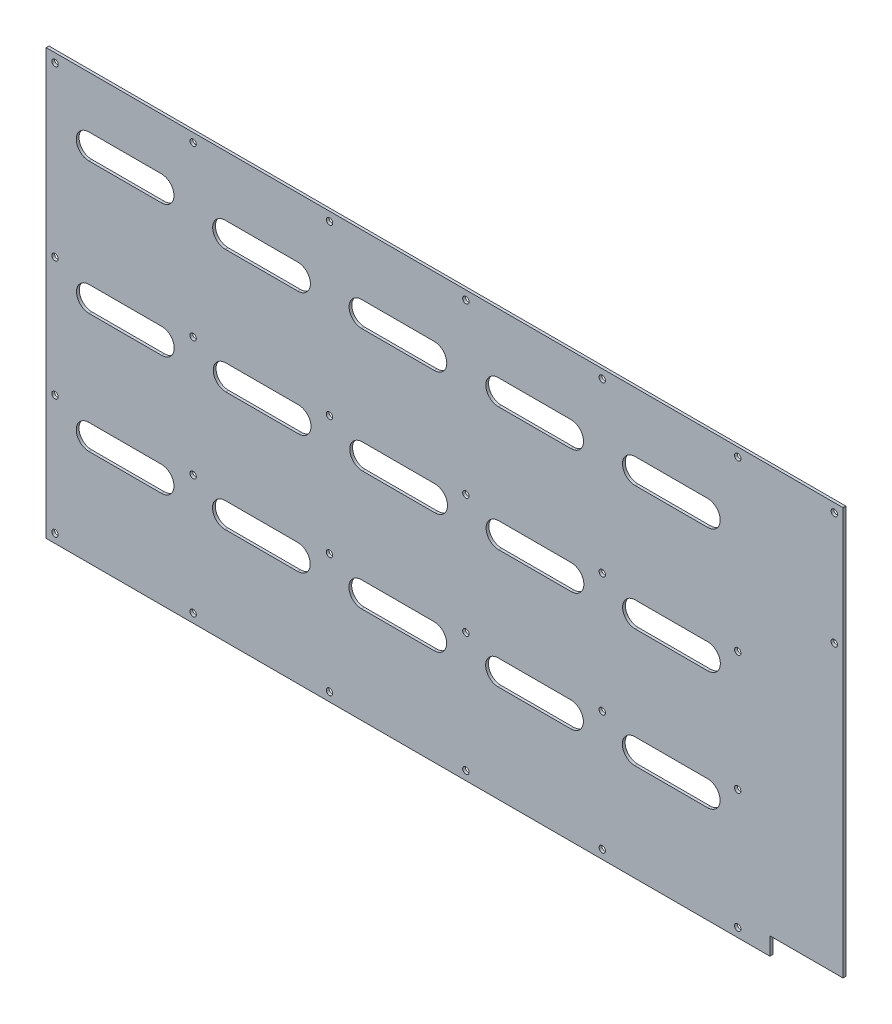
from build123d import *

# Parameters (mm, degrees)
MODEL_R             = 1.8288
BOSS_EXTRUDE2_DEPTH = 1.5875


with BuildPart() as part:
    # Model → Boss-Extrude2 (new body)
    with BuildSketch(Plane.XY):
        with BuildLine():
            ThreePointArc((0, 0.0635), (0.044901281, 0.044901281), (0.0635, 0))
            Line((0.0635, 0), (415.2265, 0))
            ThreePointArc((415.2265, 0), (415.245098719, 0.044901281), (415.29, 0.0635))
            Line((415.29, 0.0635), (415.29, 10.0965))
            ThreePointArc((415.29, 10.0965), (415.245098719, 10.204901281), (415.3535, 10.16))
            Line((415.3535, 10.16), (457.1365, 10.16))
            ThreePointArc((457.1365, 10.16), (457.155098719, 10.204901281), (457.2, 10.2235))
            Line((457.2, 10.2235), (457.2, 243.7765))
            ThreePointArc((457.2, 243.7765), (457.155098719, 243.795098719), (457.1365, 243.84))
            Line((457.1365, 243.84), (0.0635, 243.84))
            ThreePointArc((0.0635, 243.84), (0.044901281, 243.795098719), (0, 243.7765))
            Line((0, 243.7765), (0, 0.0635))
        make_face()
        with Locations((5.08, 5.08)):
            Circle(MODEL_R, mode=Mode.SUBTRACT)
        with Locations((84.328, 5.08)):
            Circle(MODEL_R, mode=Mode.SUBTRACT)
        with Locations((162.56, 5.08)):
            Circle(MODEL_R, mode=Mode.SUBTRACT)
        with Locations((5.08, 73.66)):
            Circle(MODEL_R, mode=Mode.SUBTRACT)
        with BuildLine():
            ThreePointArc((24.423491284, 69.864294681), (24.486850673, 69.928074512), (24.550490667, 69.864574667))
            Line((24.550490667, 69.864574667), (66.079490667, 69.864574667))
            ThreePointArc((66.079490667, 69.864574667), (66.142990667, 69.928074667), (66.206490667, 69.864574667))
            ThreePointArc((66.206490667, 69.864574667), (66.206490512, 69.864434673), (66.206490049, 69.864294681))
            ThreePointArc((66.206490049, 69.864294681), (73.343728337, 62.632017), (66.142990667, 55.462959333))
            Line((66.142990667, 55.462959333), (24.486990667, 55.462959333))
            ThreePointArc((24.486990667, 55.462959333), (17.286252997, 62.632017), (24.423491284, 69.864294681))
        make_face(mode=Mode.SUBTRACT)
        with Locations((84.328, 73.66)):
            Circle(MODEL_R, mode=Mode.SUBTRACT)
        with BuildLine():
            ThreePointArc((102.595635284, 70.154387347), (102.658994673, 70.218167179), (102.722634667, 70.154667333))
            Line((102.722634667, 70.154667333), (144.251634667, 70.154667333))
            ThreePointArc((144.251634667, 70.154667333), (144.315134667, 70.218167333), (144.378634667, 70.154667333))
            ThreePointArc((144.378634667, 70.154667333), (144.378634512, 70.15452734), (144.378634049, 70.154387347))
            ThreePointArc((144.378634049, 70.154387347), (151.515872337, 62.922109667), (144.315134667, 55.753052))
            Line((144.315134667, 55.753052), (102.659134667, 55.753052))
            ThreePointArc((102.659134667, 55.753052), (95.458396997, 62.922109667), (102.595635284, 70.154387347))
        make_face(mode=Mode.SUBTRACT)
        with Locations((162.56, 73.66)):
            Circle(MODEL_R, mode=Mode.SUBTRACT)
        with BuildLine():
            ThreePointArc((180.831401284, 69.892675347), (180.894760673, 69.956455179), (180.958400667, 69.892955333))
            Line((180.958400667, 69.892955333), (222.487400667, 69.892955333))
            ThreePointArc((222.487400667, 69.892955333), (222.550900667, 69.956455333), (222.614400667, 69.892955333))
            ThreePointArc((222.614400667, 69.892955333), (222.614400512, 69.89281534), (222.614400049, 69.892675347))
            ThreePointArc((222.614400049, 69.892675347), (229.751638337, 62.660397667), (222.550900667, 55.49134))
            Line((222.550900667, 55.49134), (180.894900667, 55.49134))
            ThreePointArc((180.894900667, 55.49134), (173.694162997, 62.660397667), (180.831401284, 69.892675347))
        make_face(mode=Mode.SUBTRACT)
        with Locations((240.792, 5.08)):
            Circle(MODEL_R, mode=Mode.SUBTRACT)
        with Locations((319.024, 5.08)):
            Circle(MODEL_R, mode=Mode.SUBTRACT)
        with Locations((396.748, 5.08)):
            Circle(MODEL_R, mode=Mode.SUBTRACT)
        with Locations((240.792, 73.66)):
            Circle(MODEL_R, mode=Mode.SUBTRACT)
        with BuildLine():
            ThreePointArc((259.275886617, 70.272664014), (259.339246007, 70.336443846), (259.402886, 70.272944))
            Line((259.402886, 70.272944), (300.931886, 70.272944))
            ThreePointArc((300.931886, 70.272944), (300.995386, 70.336444), (301.058886, 70.272944))
            ThreePointArc((301.058886, 70.272944), (301.058885846, 70.272804007), (301.058885383, 70.272664014))
            ThreePointArc((301.058885383, 70.272664014), (308.19612367, 63.040386333), (300.995386, 55.871328667))
            Line((300.995386, 55.871328667), (259.339386, 55.871328667))
            ThreePointArc((259.339386, 55.871328667), (252.13864833, 63.040386333), (259.275886617, 70.272664014))
        make_face(mode=Mode.SUBTRACT)
        with Locations((319.024, 73.66)):
            Circle(MODEL_R, mode=Mode.SUBTRACT)
        with BuildLine():
            ThreePointArc((337.687723951, 70.325532014), (337.75108334, 70.389311846), (337.814723333, 70.325812))
            Line((337.814723333, 70.325812), (379.343723333, 70.325812))
            ThreePointArc((379.343723333, 70.325812), (379.407223333, 70.389312), (379.470723333, 70.325812))
            ThreePointArc((379.470723333, 70.325812), (379.470723179, 70.325672007), (379.470722716, 70.325532014))
            ThreePointArc((379.470722716, 70.325532014), (386.607961003, 63.093254333), (379.407223333, 55.924196667))
            Line((379.407223333, 55.924196667), (337.751223333, 55.924196667))
            ThreePointArc((337.751223333, 55.924196667), (330.550485663, 63.093254333), (337.687723951, 70.325532014))
        make_face(mode=Mode.SUBTRACT)
        with Locations((396.748, 73.66)):
            Circle(MODEL_R, mode=Mode.SUBTRACT)
        with BuildLine():
            ThreePointArc((24.575717951, 138.462604014), (24.63907734, 138.526383846), (24.702717333, 138.462884))
            Line((24.702717333, 138.462884), (66.231717333, 138.462884))
            ThreePointArc((66.231717333, 138.462884), (66.295217333, 138.526384), (66.358717333, 138.462884))
            ThreePointArc((66.358717333, 138.462884), (66.358717179, 138.462744007), (66.358716716, 138.462604014))
            ThreePointArc((66.358716716, 138.462604014), (73.495955003, 131.230326333), (66.295217333, 124.061268667))
            Line((66.295217333, 124.061268667), (24.639217333, 124.061268667))
            ThreePointArc((24.639217333, 124.061268667), (17.438479663, 131.230326333), (24.575717951, 138.462604014))
        make_face(mode=Mode.SUBTRACT)
        with Locations((5.08, 142.24)):
            Circle(MODEL_R, mode=Mode.SUBTRACT)
        with Locations((84.328, 142.24)):
            Circle(MODEL_R, mode=Mode.SUBTRACT)
        with BuildLine():
            ThreePointArc((103.033043284, 138.709714014), (103.096402673, 138.773493846), (103.160042667, 138.709994))
            Line((103.160042667, 138.709994), (144.689042667, 138.709994))
            ThreePointArc((144.689042667, 138.709994), (144.752542667, 138.773494), (144.816042667, 138.709994))
            ThreePointArc((144.816042667, 138.709994), (144.816042512, 138.709854007), (144.816042049, 138.709714014))
            ThreePointArc((144.816042049, 138.709714014), (151.953280337, 131.477436333), (144.752542667, 124.308378667))
            Line((144.752542667, 124.308378667), (103.096542667, 124.308378667))
            ThreePointArc((103.096542667, 124.308378667), (95.895804997, 131.477436333), (103.033043284, 138.709714014))
        make_face(mode=Mode.SUBTRACT)
        with Locations((162.56, 142.24)):
            Circle(MODEL_R, mode=Mode.SUBTRACT)
        with BuildLine():
            ThreePointArc((181.327167284, 138.620484681), (181.390526673, 138.684264512), (181.454166667, 138.620764667))
            Line((181.454166667, 138.620764667), (222.983166667, 138.620764667))
            ThreePointArc((222.983166667, 138.620764667), (223.046666667, 138.684264667), (223.110166667, 138.620764667))
            ThreePointArc((223.110166667, 138.620764667), (223.110166512, 138.620624673), (223.110166049, 138.620484681))
            ThreePointArc((223.110166049, 138.620484681), (230.247404337, 131.388207), (223.046666667, 124.219149333))
            Line((223.046666667, 124.219149333), (181.390666667, 124.219149333))
            ThreePointArc((181.390666667, 124.219149333), (174.189928997, 131.388207), (181.327167284, 138.620484681))
        make_face(mode=Mode.SUBTRACT)
        with BuildLine():
            ThreePointArc((24.435133284, 214.173060014), (24.498492673, 214.236839846), (24.562132667, 214.17334))
            Line((24.562132667, 214.17334), (66.091132667, 214.17334))
            ThreePointArc((66.091132667, 214.17334), (66.154632667, 214.23684), (66.218132667, 214.17334))
            ThreePointArc((66.218132667, 214.17334), (66.218132512, 214.173200007), (66.218132049, 214.173060014))
            ThreePointArc((66.218132049, 214.173060014), (73.355370337, 206.940782333), (66.154632667, 199.771724667))
            Line((66.154632667, 199.771724667), (24.498632667, 199.771724667))
            ThreePointArc((24.498632667, 199.771724667), (17.297894997, 206.940782333), (24.435133284, 214.173060014))
        make_face(mode=Mode.SUBTRACT)
        with Locations((5.08, 238.76)):
            Circle(MODEL_R, mode=Mode.SUBTRACT)
        with Locations((84.328, 238.76)):
            Circle(MODEL_R, mode=Mode.SUBTRACT)
        with BuildLine():
            ThreePointArc((102.684258617, 209.423534014), (102.747618007, 209.487313846), (102.811258, 209.423814))
            Line((102.811258, 209.423814), (144.340258, 209.423814))
            ThreePointArc((144.340258, 209.423814), (144.403758, 209.487314), (144.467258, 209.423814))
            ThreePointArc((144.467258, 209.423814), (144.467257846, 209.423674007), (144.467257383, 209.423534014))
            ThreePointArc((144.467257383, 209.423534014), (151.60449567, 202.191256333), (144.403758, 195.022198667))
            Line((144.403758, 195.022198667), (102.747758, 195.022198667))
            ThreePointArc((102.747758, 195.022198667), (95.54702033, 202.191256333), (102.684258617, 209.423534014))
        make_face(mode=Mode.SUBTRACT)
        with BuildLine():
            ThreePointArc((180.920024617, 209.161822014), (180.983384007, 209.225601846), (181.047024, 209.162102))
            Line((181.047024, 209.162102), (222.576024, 209.162102))
            ThreePointArc((222.576024, 209.162102), (222.639524, 209.225602), (222.703024, 209.162102))
            ThreePointArc((222.703024, 209.162102), (222.703023846, 209.161962007), (222.703023383, 209.161822014))
            ThreePointArc((222.703023383, 209.161822014), (229.84026167, 201.929544333), (222.639524, 194.760486667))
            Line((222.639524, 194.760486667), (180.983524, 194.760486667))
            ThreePointArc((180.983524, 194.760486667), (173.78278633, 201.929544333), (180.920024617, 209.161822014))
        make_face(mode=Mode.SUBTRACT)
        with Locations((162.56, 238.76)):
            Circle(MODEL_R, mode=Mode.SUBTRACT)
        with BuildLine():
            ThreePointArc((259.544630617, 138.569990014), (259.607990007, 138.633769846), (259.67163, 138.57027))
            Line((259.67163, 138.57027), (301.20063, 138.57027))
            ThreePointArc((301.20063, 138.57027), (301.26413, 138.63377), (301.32763, 138.57027))
            ThreePointArc((301.32763, 138.57027), (301.327629846, 138.570130007), (301.327629383, 138.569990014))
            ThreePointArc((301.327629383, 138.569990014), (308.46486767, 131.337712333), (301.26413, 124.168654667))
            Line((301.26413, 124.168654667), (259.60813, 124.168654667))
            ThreePointArc((259.60813, 124.168654667), (252.40739233, 131.337712333), (259.544630617, 138.569990014))
        make_face(mode=Mode.SUBTRACT)
        with Locations((240.792, 142.24)):
            Circle(MODEL_R, mode=Mode.SUBTRACT)
        with Locations((319.024, 142.24)):
            Circle(MODEL_R, mode=Mode.SUBTRACT)
        with BuildLine():
            ThreePointArc((337.844915284, 138.378166681), (337.908274673, 138.441946512), (337.971914667, 138.378446667))
            Line((337.971914667, 138.378446667), (379.500914667, 138.378446667))
            ThreePointArc((379.500914667, 138.378446667), (379.564414667, 138.441946667), (379.627914667, 138.378446667))
            ThreePointArc((379.627914667, 138.378446667), (379.627914512, 138.378306673), (379.627914049, 138.378166681))
            ThreePointArc((379.627914049, 138.378166681), (386.765152337, 131.145889), (379.564414667, 123.976831333))
            Line((379.564414667, 123.976831333), (337.908414667, 123.976831333))
            ThreePointArc((337.908414667, 123.976831333), (330.707676997, 131.145889), (337.844915284, 138.378166681))
        make_face(mode=Mode.SUBTRACT)
        with Locations((396.748, 142.24)):
            Circle(MODEL_R, mode=Mode.SUBTRACT)
        with Locations((452.12, 173.99)):
            Circle(MODEL_R, mode=Mode.SUBTRACT)
        with BuildLine():
            ThreePointArc((259.364509951, 209.541810681), (259.42786934, 209.605590512), (259.491509333, 209.542090667))
            Line((259.491509333, 209.542090667), (301.020509333, 209.542090667))
            ThreePointArc((301.020509333, 209.542090667), (301.084009333, 209.605590667), (301.147509333, 209.542090667))
            ThreePointArc((301.147509333, 209.542090667), (301.147509179, 209.541950673), (301.147508716, 209.541810681))
            ThreePointArc((301.147508716, 209.541810681), (308.284747003, 202.309533), (301.084009333, 195.140475333))
            Line((301.084009333, 195.140475333), (259.428009333, 195.140475333))
            ThreePointArc((259.428009333, 195.140475333), (252.227271663, 202.309533), (259.364509951, 209.541810681))
        make_face(mode=Mode.SUBTRACT)
        with Locations((240.792, 238.76)):
            Circle(MODEL_R, mode=Mode.SUBTRACT)
        with Locations((319.024, 238.76)):
            Circle(MODEL_R, mode=Mode.SUBTRACT)
        with BuildLine():
            ThreePointArc((337.776347284, 209.594678681), (337.839706673, 209.658458512), (337.903346667, 209.594958667))
            Line((337.903346667, 209.594958667), (379.432346667, 209.594958667))
            ThreePointArc((379.432346667, 209.594958667), (379.495846667, 209.658458667), (379.559346667, 209.594958667))
            ThreePointArc((379.559346667, 209.594958667), (379.559346512, 209.594818673), (379.559346049, 209.594678681))
            ThreePointArc((379.559346049, 209.594678681), (386.696584337, 202.362401), (379.495846667, 195.193343333))
            Line((379.495846667, 195.193343333), (337.839846667, 195.193343333))
            ThreePointArc((337.839846667, 195.193343333), (330.639108997, 202.362401), (337.776347284, 209.594678681))
        make_face(mode=Mode.SUBTRACT)
        with Locations((396.748, 238.76)):
            Circle(MODEL_R, mode=Mode.SUBTRACT)
        with Locations((452.12, 238.76)):
            Circle(MODEL_R, mode=Mode.SUBTRACT)
    extrude(amount=BOSS_EXTRUDE2_DEPTH)


solid = part.part
